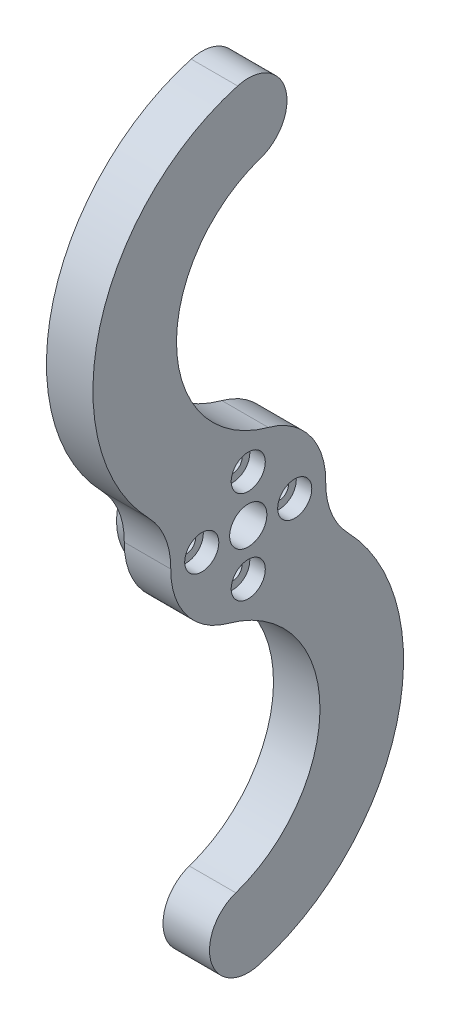
from build123d import *

# Parameters (mm, degrees)
SKETCH1_R                      = 2.4
BOSS_EXTRUDE1_DEPTH            = 6
SKETCH2_R                      = 8
SKETCH2_R_2                    = 2.4
BOSS_EXTRUDE2_DEPTH            = 3
CBORE_FOR_M2_SHCS1_D           = 2.4
CBORE_FOR_M2_SHCS1_CBORE_D     = 4.4
CBORE_FOR_M2_SHCS1_CBORE_DEPTH = 2
FILLET1_R                      = 10


with BuildPart() as part:
    # Sketch1 → Boss-Extrude1 (new body)
    with BuildSketch(Plane(origin=(0, 0, 0), x_dir=(0, 0, -1), z_dir=(1, 0, 0))):
        with BuildLine():
            ThreePointArc((9.139568575, -4.058113633), (9.024618995, 4.307696832), (2.592436286, 9.658119595))
            ThreePointArc((2.592436286, 9.658119595), (-9.251342607, 24.595099021), (1.604842351, 40.264550225))
            ThreePointArc((1.604842351, 40.264550225), (4.773868283, 46.4866715), (-1.367582481, 49.809336247))
            ThreePointArc((-1.367582481, 49.809336247), (-19.682903104, 29.384906165), (-9.139568476, 4.058113857))
            ThreePointArc((-9.139568476, 4.058113857), (-9.024618995, -4.307696832), (-2.592436049, -9.658119658))
            ThreePointArc((-2.592436049, -9.658119658), (9.25134321, -24.595098795), (-1.604841364, -40.264550265))
            ThreePointArc((-1.604841364, -40.264550265), (-4.773867143, -46.486671617), (1.367583702, -49.809336214))
            ThreePointArc((1.367583702, -49.809336214), (19.682903824, -29.384905682), (9.139568575, -4.058113633))
        make_face()
        Circle(SKETCH1_R, mode=Mode.SUBTRACT)
    extrude(amount=BOSS_EXTRUDE1_DEPTH)

    # Sketch2 → Boss-Extrude2 (add)
    with BuildSketch(Plane.ZY):
        Circle(SKETCH2_R)
        Circle(SKETCH2_R_2, mode=Mode.SUBTRACT)
    extrude(amount=BOSS_EXTRUDE2_DEPTH)

    # CBORE for M2 SHCS1 (through all)
    with Locations(Plane(origin=(6, 0, 0), x_dir=(0, 0, -1), z_dir=(1, 0, 0))):
        with Locations((0, -6), (-6, 0), (0, 6), (6, 0)):
            CounterBoreHole(CBORE_FOR_M2_SHCS1_D / 2, CBORE_FOR_M2_SHCS1_CBORE_D / 2, CBORE_FOR_M2_SHCS1_CBORE_DEPTH)

    # Fillet1
    fillet1_edges = [part.edges().sort_by_distance(p)[0] for p in [
        (3, 4.058113857, 9.139568476),
        (3, -4.058113633, -9.139568575),
    ]]
    fillet(fillet1_edges, radius=FILLET1_R)


solid = part.part
